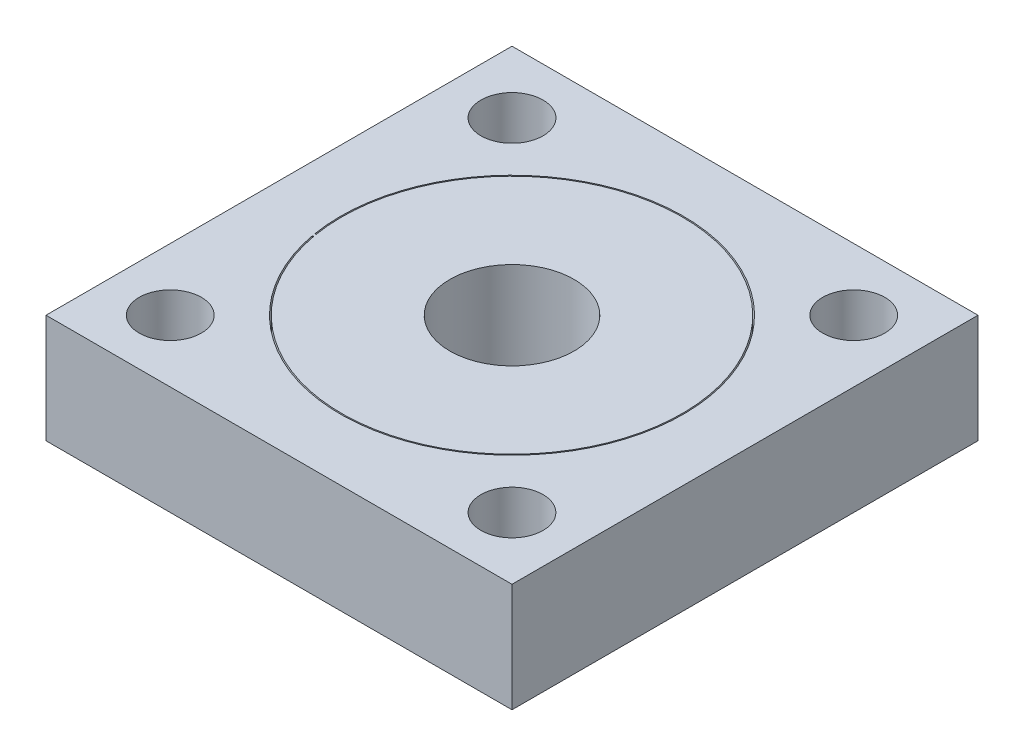
from build123d import *

# Parameters (mm, degrees)
SKETCH1_W                    = 30
SKETCH1_H                    = 30
SKETCH1_R                    = 4
BOSS_EXTRUDE1_DEPTH          = 7
CUT_EXTRUDE_THIN1_DEPTH      = 1
CUT_EXTRUDE_THIN1_DEPTH_BACK = 10
SKETCH3_R                    = 2
CUT_EXTRUDE1_DEPTH           = 10
CIRPATTERN1_COUNT            = 4


with BuildPart() as part:
    # Sketch1 → Boss-Extrude1 (new body)
    with BuildSketch(Plane(origin=(0, 0, 0), x_dir=(1, 0, 0), z_dir=(0, 1, 0))):
        Rectangle(SKETCH1_W, SKETCH1_H)
        Circle(SKETCH1_R, mode=Mode.SUBTRACT)
    extrude(amount=BOSS_EXTRUDE1_DEPTH)

    # Sketch2 → Cut-Extrude-Thin1 (cut, two sides)
    with BuildSketch(Plane.XZ) as cut_extrude_thin1_sk:
        with BuildLine():
            ThreePointArc((-10.891369385, 1.805456431), (10.875199295, -1.900431606), (-10.858201017, 1.995262057))
            Line((-10.858201017, 1.995262057), (-10.779518401, 1.980803636))
            ThreePointArc((-10.779518401, 1.980803636), (10.796393503, -1.886660363), (-10.812446418, 1.792373414))
            Line((-10.812446418, 1.792373414), (-10.891369385, 1.805456431))
        make_face()
    extrude(amount=CUT_EXTRUDE_THIN1_DEPTH, mode=Mode.SUBTRACT)
    extrude(cut_extrude_thin1_sk.sketch, amount=-CUT_EXTRUDE_THIN1_DEPTH_BACK, mode=Mode.SUBTRACT)

    # Sketch3 → Cut-Extrude1 (cut)
    with BuildSketch(Plane(origin=(0, 7, 0), x_dir=(1, 0, 0), z_dir=(0, 1, 0))):
        with Locations((11, 11)):
            Circle(SKETCH3_R)
    cut_extrude1 = extrude(amount=-CUT_EXTRUDE1_DEPTH, mode=Mode.SUBTRACT)

    # CirPattern1: Cut-Extrude1 ×4 about axis
    cirpattern1_axis = Axis((0, 0, 0), (0, 1, 0))
    for i in range(1, CIRPATTERN1_COUNT):
        add(cut_extrude1.rotate(cirpattern1_axis, i * 360 / CIRPATTERN1_COUNT), mode=Mode.SUBTRACT)


solid = part.part
